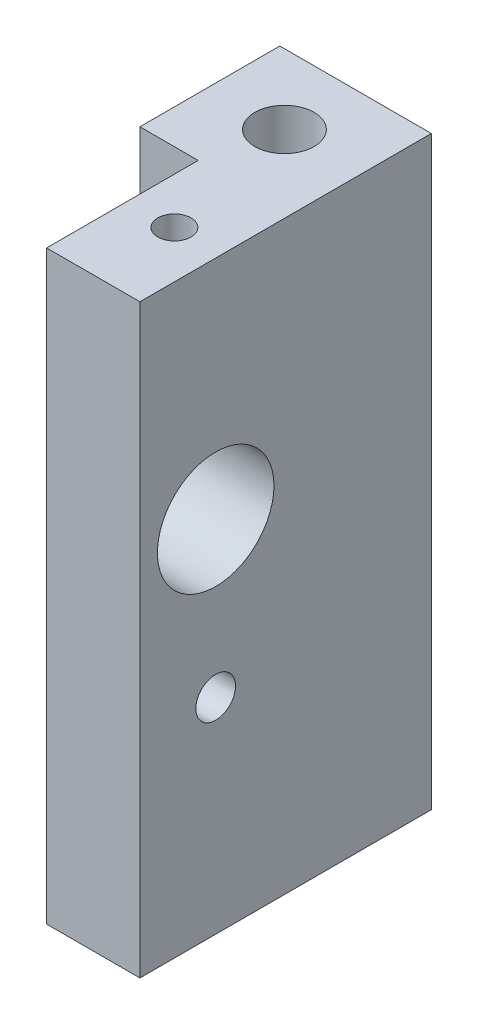
from build123d import *

# Parameters (mm, degrees)
BOSS_EXTRUDE1_DEPTH        = 39.878
F_10_32_TAPPED_HOLE1_D     = 4.0386
F_10_32_TAPPED_HOLE1_DEPTH = 39.878
F_6_32_TAPPED_HOLE1_D      = 2.7051
F_6_32_TAPPED_HOLE1_DEPTH  = 6.35
CUT_EXTRUDE1_REACH         = 12.319
SKETCH10_R                 = 3.96875
F_4_40_TAPPED_HOLE1_D      = 2.2606
F_4_40_TAPPED_HOLE1_DEPTH  = 6.35
F_4_40_TAPPED_HOLE1_TIP    = 0.679152758


with BuildPart() as part:
    # Sketch1 → Boss-Extrude1 (new body)
    with BuildSketch(Plane(origin=(0, 0, 0), x_dir=(1, 0, 0), z_dir=(0, 1, 0))):
        Polygon((0, 0), (-3.96875, 0), (-3.96875, 9.525), (6.35, 9.525), (6.35, -10.31875), (0, -10.31875), align=None)
    extrude(amount=BOSS_EXTRUDE1_DEPTH)

    # #10-32 Tapped Hole1
    with Locations(Plane(origin=(0, 39.878, 0), x_dir=(1, 0, 0), z_dir=(0, 1, 0))):
        with Locations((1.11125, 4.7625)):
            Hole(F_10_32_TAPPED_HOLE1_D / 2, depth=F_10_32_TAPPED_HOLE1_DEPTH)

    # #6-32 Tapped Hole1
    with Locations(Plane.ZY):
        with Locations((5.159375, 13.97254)):
            Hole(F_6_32_TAPPED_HOLE1_D / 2, depth=F_6_32_TAPPED_HOLE1_DEPTH)

    # Sketch10 → Cut-Extrude1 (cut, up to next)
    with BuildSketch(Plane(origin=(6.35, 0, 0), x_dir=(0, 0, -1), z_dir=(1, 0, 0)), mode=Mode.PRIVATE) as cut_extrude1_sk1:
        with Locations((-5.159375, 24.47254)):
            Circle(SKETCH10_R)
    cut_extrude1_tool1 = extrude(cut_extrude1_sk1.sketch, amount=-CUT_EXTRUDE1_REACH, mode=Mode.PRIVATE) & part.part
    add(cut_extrude1_tool1.solids().sort_by_distance((6.35, 24.47254, 5.159375))[0], mode=Mode.SUBTRACT)

    # #4-40 Tapped Hole1
    with Locations(Plane(origin=(0, 39.878, 0), x_dir=(1, 0, 0), z_dir=(0, 1, 0))):
        with Locations((3.14325, -4.7625)):
            Hole(F_4_40_TAPPED_HOLE1_D / 2, depth=F_4_40_TAPPED_HOLE1_DEPTH)
            with Locations((0, 0, -(F_4_40_TAPPED_HOLE1_DEPTH + F_4_40_TAPPED_HOLE1_TIP / 2))):  # 118° drill point
                Cone(0, F_4_40_TAPPED_HOLE1_D / 2, F_4_40_TAPPED_HOLE1_TIP, mode=Mode.SUBTRACT)


solid = part.part
